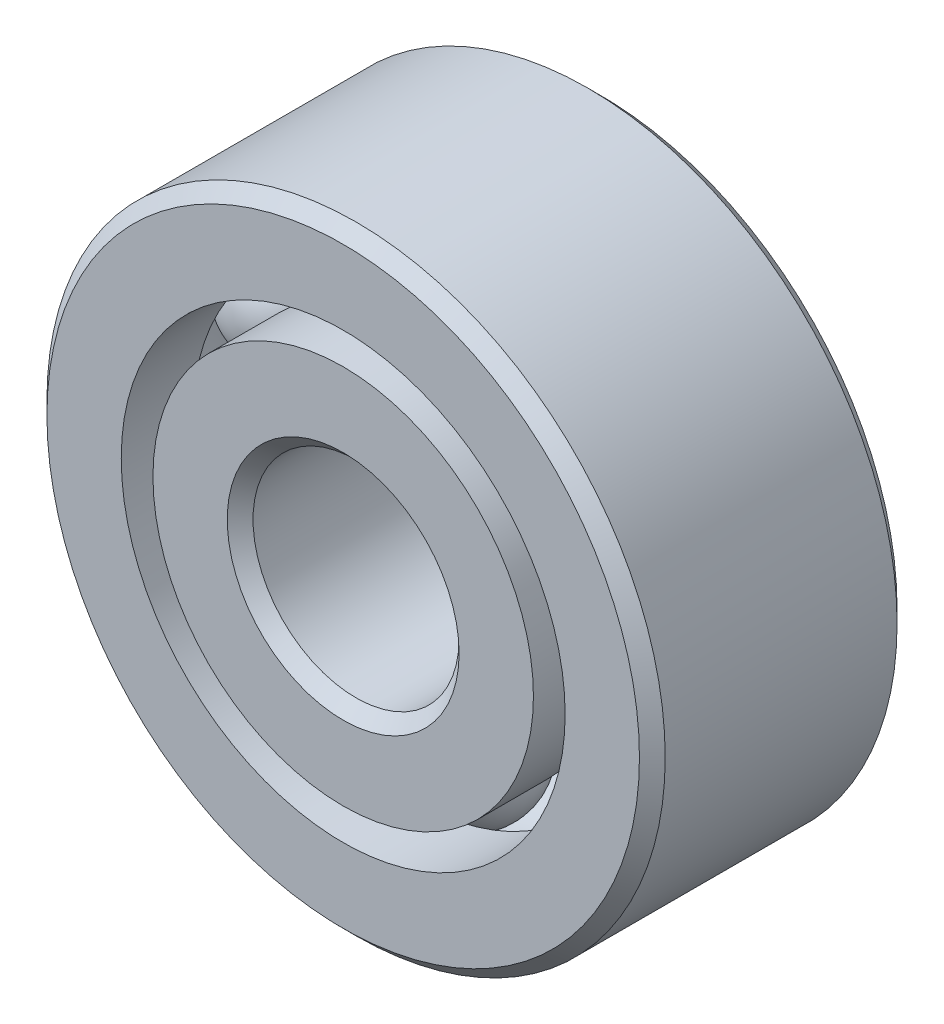
from build123d import *

# Parameters (mm, degrees)
CIRPATTERN1_COUNT = 6


with BuildPart() as part:
    # Sketch1 → Revolve1 (revolve)
    with BuildSketch(Plane(origin=(0, 0, 0), x_dir=(0, 0, -1), z_dir=(1, 0, 0))):
        with BuildLine():
            Line((1.7859375, 4.7625), (-1.7859375, 4.7625))
            Line((-1.7859375, 4.7625), (-1.984375, 4.5640625))
            Line((-1.984375, 4.5640625), (-1.984375, 3.419230769))
            Line((-1.984375, 3.419230769), (-0.881944444, 3.419230769))
            ThreePointArc((-0.881944444, 3.419230769), (0, 4.090136422), (0.881944444, 3.419230769))
            Line((0.881944444, 3.419230769), (1.984375, 3.419230769))
            Line((1.984375, 3.419230769), (1.984375, 4.5640625))
            Line((1.984375, 4.5640625), (1.7859375, 4.7625))
        make_face()
    revolve(axis=Axis((0, 0, 1.984375), (0, 0, -1)))


with BuildPart() as body_2:
    # Sketch3 → Revolve3 (revolve)
    with BuildSketch(Plane(origin=(0, 0, 0), x_dir=(0, 0, -1), z_dir=(1, 0, 0))):
        with BuildLine():
            Line((-1.984375, 2.930769231), (-0.881944444, 2.930769231))
            ThreePointArc((-0.881944444, 2.930769231), (0, 2.259863578), (0.881944444, 2.930769231))
            Line((0.881944444, 2.930769231), (1.984375, 2.930769231))
            Line((1.984375, 2.930769231), (1.984375, 1.7859375))
            Line((1.984375, 1.7859375), (1.7859375, 1.5875))
            Line((1.7859375, 1.5875), (-1.7859375, 1.5875))
            Line((-1.7859375, 1.5875), (-1.984375, 1.7859375))
            Line((-1.984375, 1.7859375), (-1.984375, 2.930769231))
        make_face()
    revolve(axis=Axis((0, 0, 1.984375), (0, 0, -1)))


with BuildPart() as body_3:
    # Sketch4 → Revolve4 (revolve)
    with BuildSketch(Plane(origin=(0, 0, 0), x_dir=(0, 0, -1), z_dir=(1, 0, 0))):
        with BuildLine():
            Line((-0.915136422, 3.175), (0.915136422, 3.175))
            ThreePointArc((0.915136422, 3.175), (0, 4.090136422), (-0.915136422, 3.175))
        make_face()
    revolve(axis=Axis((0, 3.175, 0.915136422), (0, 0, -1)))


with BuildPart() as cirpattern1_1:
    # CirPattern1: pattern copy
    add(body_3.part.rotate(Axis((0, 0, 0), (0, 0, 1)), 1 * 360 / CIRPATTERN1_COUNT))


with BuildPart() as cirpattern1_2:
    # CirPattern1: pattern copy
    add(body_3.part.rotate(Axis((0, 0, 0), (0, 0, 1)), 2 * 360 / CIRPATTERN1_COUNT))


with BuildPart() as cirpattern1_3:
    # CirPattern1: pattern copy
    add(body_3.part.rotate(Axis((0, 0, 0), (0, 0, 1)), 3 * 360 / CIRPATTERN1_COUNT))


with BuildPart() as cirpattern1_4:
    # CirPattern1: pattern copy
    add(body_3.part.rotate(Axis((0, 0, 0), (0, 0, 1)), 4 * 360 / CIRPATTERN1_COUNT))


with BuildPart() as cirpattern1_5:
    # CirPattern1: pattern copy
    add(body_3.part.rotate(Axis((0, 0, 0), (0, 0, 1)), 5 * 360 / CIRPATTERN1_COUNT))


solid = Compound([part.part, body_2.part, body_3.part, cirpattern1_1.part, cirpattern1_2.part, cirpattern1_3.part, cirpattern1_4.part, cirpattern1_5.part])
